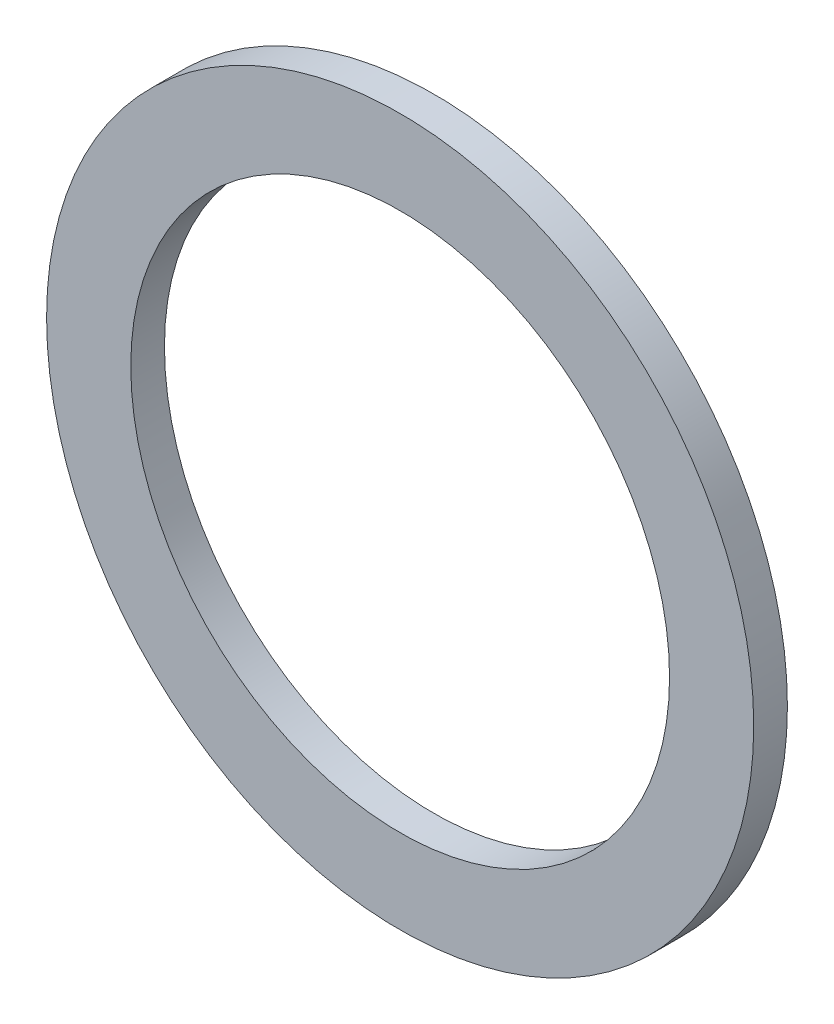
from build123d import *

# Parameters (mm, degrees)
ESQUISSE1_R      = 10.5
ESQUISSE1_R_2    = 8
EXTRUSION1_DEPTH = 0.5


with BuildPart() as part:
    # Esquisse1 → Extrusion1 (new body, symmetric)
    with BuildSketch(Plane.XY):
        Circle(ESQUISSE1_R)
        Circle(ESQUISSE1_R_2, mode=Mode.SUBTRACT)
    extrude(amount=EXTRUSION1_DEPTH, both=True)


solid = part.part
